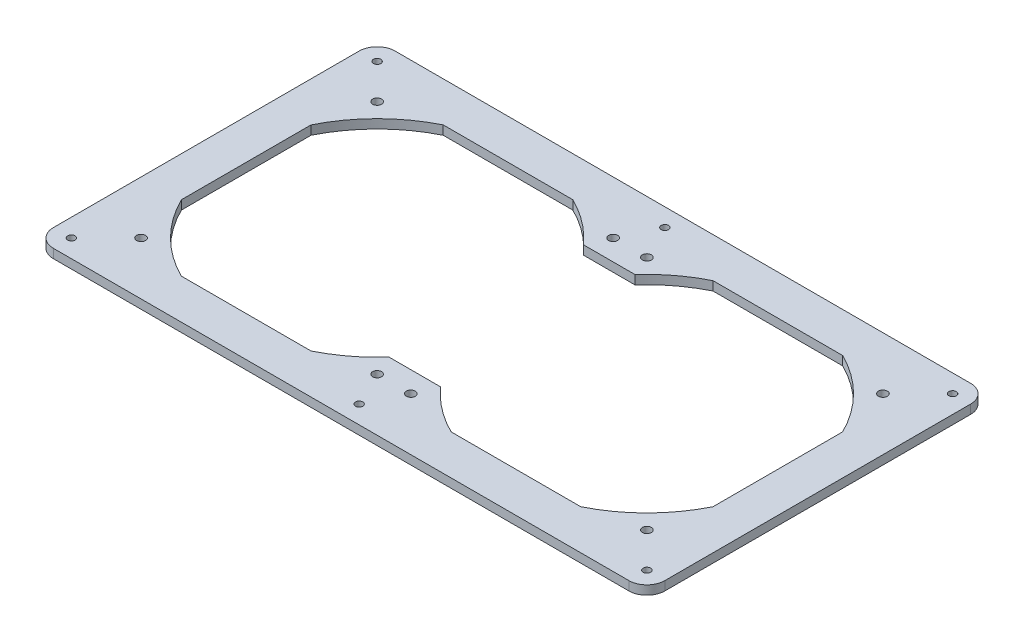
from build123d import *

# Parameters (mm, degrees)
SKETCH1_W           = 120
SKETCH1_H           = 120
SKETCH1_W_2         = 116.5
SKETCH1_H_2         = 116.5
SKETCH1_R           = 2
BOSS_EXTRUDE1_DEPTH = 4
SKETCH2_W           = 272
SKETCH2_H           = 152
SKETCH2_R           = 1.65
SKETCH2_W_2         = 240
SKETCH2_H_2         = 120
BOSS_EXTRUDE2_DEPTH = 4
FILLET1_R           = 8
SKETCH3_W           = 120
SKETCH3_H           = 86.50757595
CUT_EXTRUDE3_DEPTH  = 211.256985615


with BuildPart() as part:
    # Sketch1 → Boss-Extrude1 (new body)
    with BuildSketch(Plane(origin=(0, 0, 0), x_dir=(1, 0, 0), z_dir=(0, 1, 0))):
        Rectangle(SKETCH1_W, SKETCH1_H)
        Rectangle(SKETCH1_W_2, SKETCH1_H_2, mode=Mode.SUBTRACT)
        with BuildLine():
            Line((-58.25, -58.25), (-28.843326785, -58.25))
            ThreePointArc((-28.843326785, -58.25), (-45.961940777, -45.961940777), (-58.25, -28.843326785))
            Line((-58.25, -28.843326785), (-58.25, -58.25))
        make_face()
        with Locations(Location((-52.5, -52.5, 0), (0, 0, 270))):
            Circle(SKETCH1_R, mode=Mode.SUBTRACT)
        with BuildLine():
            Line((-58.25, 58.25), (-58.25, 28.843326785))
            ThreePointArc((-58.25, 28.843326785), (-45.961940777, 45.961940777), (-28.843326785, 58.25))
            Line((-28.843326785, 58.25), (-58.25, 58.25))
        make_face()
        with Locations(Location((-52.5, 52.5, 0), (0, 0, 270))):
            Circle(SKETCH1_R, mode=Mode.SUBTRACT)
        with BuildLine():
            ThreePointArc((28.843326785, 58.25), (45.961940777, 45.961940777), (58.25, 28.843326785))
            Line((58.25, 28.843326785), (58.25, 58.25))
            Line((58.25, 58.25), (28.843326785, 58.25))
        make_face()
        with Locations(Location((52.5, 52.5, 0), (0, 0, 270))):
            Circle(SKETCH1_R, mode=Mode.SUBTRACT)
        with BuildLine():
            Line((28.843326785, -58.25), (58.25, -58.25))
            Line((58.25, -58.25), (58.25, -28.843326785))
            ThreePointArc((58.25, -28.843326785), (45.961940777, -45.961940777), (28.843326785, -58.25))
        make_face()
        with Locations(Location((52.5, -52.5, 0), (0, 0, 270))):
            Circle(SKETCH1_R, mode=Mode.SUBTRACT)
    boss_extrude1 = extrude(amount=BOSS_EXTRUDE1_DEPTH)

    # Mirror1: Boss-Extrude1 across plane
    add(boss_extrude1.mirror(Plane(origin=(60, 4, 0), x_dir=(0, 0, 1), z_dir=(-1, 0, 0))))

    # Sketch2 → Boss-Extrude2 (add)
    with BuildSketch(Plane(origin=(0, 0, 0), x_dir=(1, 0, 0), z_dir=(0, 1, 0))):
        with Locations((60, 0)):
            Rectangle(SKETCH2_W, SKETCH2_H)
        with Locations(Location((188, 68, 0), (0, 0, 270))):
            Circle(SKETCH2_R, mode=Mode.SUBTRACT)
        with Locations(Location((60, 68, 0), (0, 0, 270))):
            Circle(SKETCH2_R, mode=Mode.SUBTRACT)
        with Locations(Location((-68, 68, 0), (0, 0, 270))):
            Circle(SKETCH2_R, mode=Mode.SUBTRACT)
        with Locations(Location((-68, -68, 0), (0, 0, 90))):
            Circle(SKETCH2_R, mode=Mode.SUBTRACT)
        with Locations(Location((60, -68, 0), (0, 0, 90))):
            Circle(SKETCH2_R, mode=Mode.SUBTRACT)
        with Locations(Location((188, -68, 0), (0, 0, 90))):
            Circle(SKETCH2_R, mode=Mode.SUBTRACT)
        with Locations((60, 0)):
            Rectangle(SKETCH2_W_2, SKETCH2_H_2, mode=Mode.SUBTRACT)
    extrude(amount=BOSS_EXTRUDE2_DEPTH)

    # Fillet1
    fillet1_edges = [part.edges().sort_by_distance(p)[0] for p in [
        (196, 2, -76),
        (-76, 2, -76),
        (-76, 2, 76),
        (196, 2, 76),
    ]]
    fillet(fillet1_edges, radius=FILLET1_R)

    # Sketch3 → Cut-Extrude3 (cut, through all)
    with BuildSketch(Plane(origin=(0, 0, 0), x_dir=(1, 0, 0), z_dir=(0, 1, 0))):
        with Locations((60, 0)):
            Rectangle(SKETCH3_W, SKETCH3_H)
    extrude(amount=CUT_EXTRUDE3_DEPTH, mode=Mode.SUBTRACT)


solid = part.part
